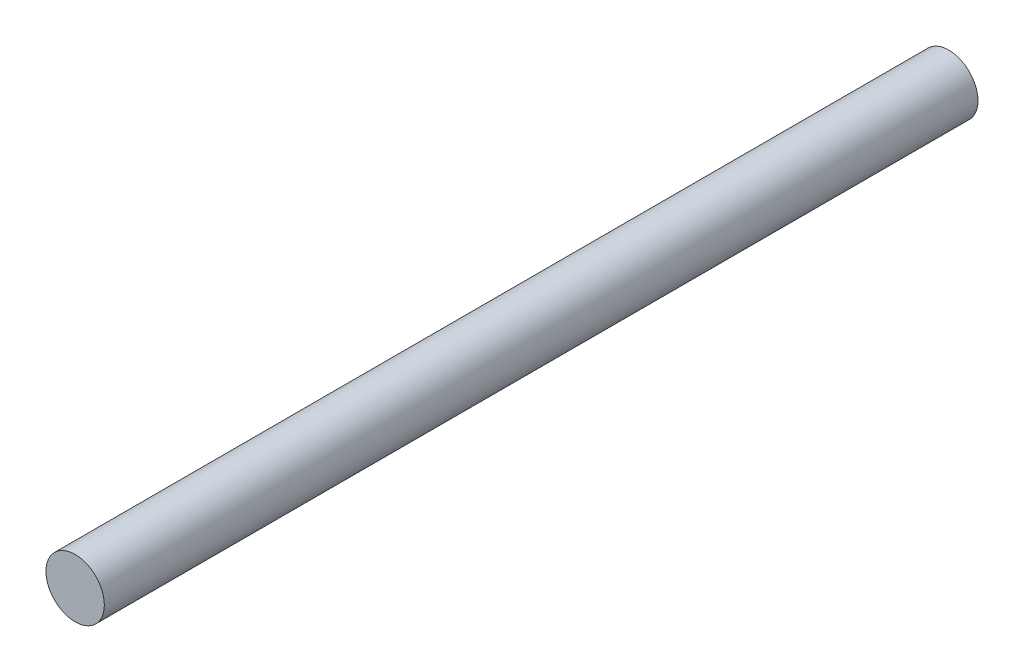
from build123d import *

# Parameters (mm, degrees)
SKETCH1_R           = 3.175
BOSS_EXTRUDE1_DEPTH = 47.5


with BuildPart() as part:
    # Sketch1 → Boss-Extrude1 (new body, symmetric)
    with BuildSketch(Plane.XY):
        Circle(SKETCH1_R)
    extrude(amount=BOSS_EXTRUDE1_DEPTH, both=True)


solid = part.part
